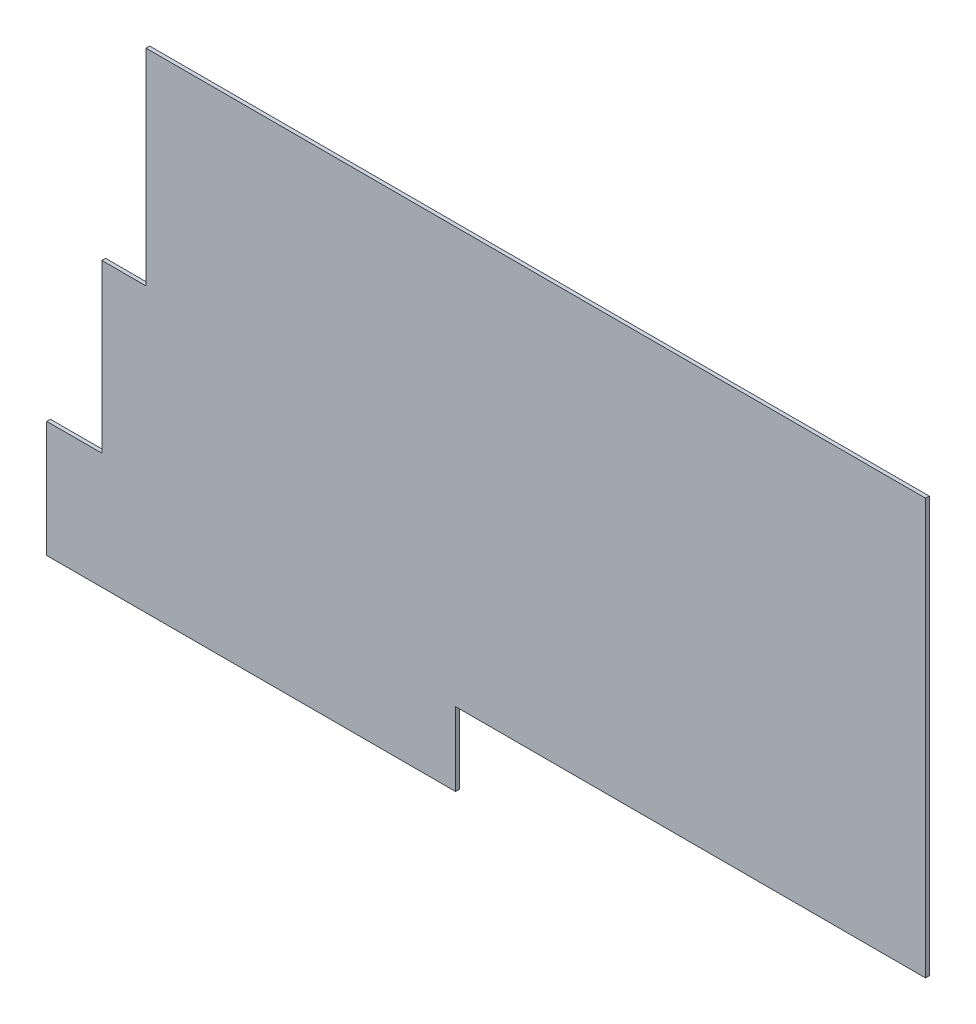
from build123d import *

# Parameters (mm, degrees)
EXTRUDE1_DEPTH = 50


with BuildPart() as part:
    # Sketch1 → Extrude1 (new body)
    with BuildSketch(Plane.XY):
        Polygon((8530, -2750), (2140, -2750), (2140, -3750), (-3420, -3750), (-3420, -2170), (-2670, -2170), (-2670, 100), (-2070, 100), (-2070, 2900), (8530, 2900), align=None)
    extrude(amount=EXTRUDE1_DEPTH)


solid = part.part
